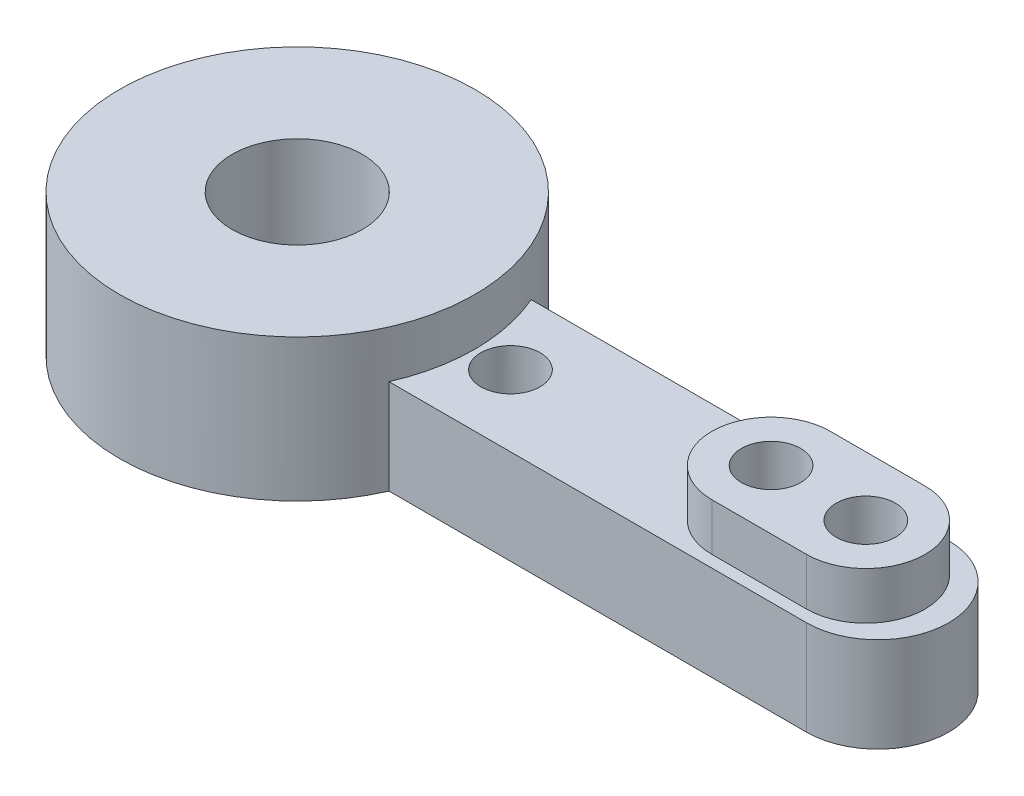
from build123d import *

# Parameters (mm, degrees)
SKETCH_1_R               = 7.5
EXTRUDE_1_DEPTH          = 4
SKETCH_1_3_R             = 7.5
EXTRUDE_2_DEPTH          = 6
EXTRUDE_3_DEPTH          = 2
HOLE_WIZARD_M3_1_D       = 2.5
SKETCH_5_R               = 2.75
CUT_EXTRUDE_1_DEPTH      = 1
CUT_EXTRUDE_1_DEPTH_BACK = 4
SKETCH_6_R               = 4
CUT_EXTRUDE_2_DEPTH      = 0.75


with BuildPart() as part:
    # 草图1 → 凸台-拉伸1 (new body)
    with BuildSketch(Plane(origin=(0, 0, 0), x_dir=(1, 0, 0), z_dir=(0, 1, 0))):
        Circle(SKETCH_1_R)
        with BuildLine():
            Line((0, 3), (24.5, 3))
            ThreePointArc((24.5, 3), (27.5, 0), (24.5, -3))
            Line((24.5, -3), (0, -3))
            ThreePointArc((0, -3), (-3, 0), (0, 3))
        make_face()
    extrude(amount=EXTRUDE_1_DEPTH)

    # 草图1<3> → 凸台-拉伸2 (add)
    with BuildSketch(Plane(origin=(0, 0, 0), x_dir=(1, 0, 0), z_dir=(0, 1, 0))):
        Circle(SKETCH_1_3_R)
    extrude(amount=EXTRUDE_2_DEPTH)

    # 草图2 → 凸台-拉伸3 (add)
    with BuildSketch(Plane(origin=(0, 4, 0), x_dir=(1, 0, 0), z_dir=(0, 1, 0))):
        with BuildLine():
            Line((20, -2.5), (24, -2.5))
            ThreePointArc((24, -2.5), (26.5, 0), (24, 2.5))
            Line((24, 2.5), (20, 2.5))
            ThreePointArc((20, 2.5), (17.5, 0), (20, -2.5))
        make_face()
    extrude(amount=EXTRUDE_3_DEPTH)

    # M3 螺纹孔1 (through all)
    with Locations(Plane.XZ):
        with Locations((20, 0), (24, 0), (0, 0), (9, 0)):
            Hole(HOLE_WIZARD_M3_1_D / 2)

    # 草图5 → 切除-拉伸1 (cut, two sides)
    with BuildSketch(Plane(origin=(0, 6, 0), x_dir=(1, 0, 0), z_dir=(0, 1, 0))) as cut_extrude_1_sk:
        Circle(SKETCH_5_R)
    extrude(amount=CUT_EXTRUDE_1_DEPTH, mode=Mode.SUBTRACT)
    extrude(cut_extrude_1_sk.sketch, amount=-CUT_EXTRUDE_1_DEPTH_BACK, mode=Mode.SUBTRACT)

    # 草图6 → 切除-拉伸2 (cut)
    with BuildSketch(Plane.XZ):
        Circle(SKETCH_6_R)
    extrude(amount=-CUT_EXTRUDE_2_DEPTH, mode=Mode.SUBTRACT)


solid = part.part
